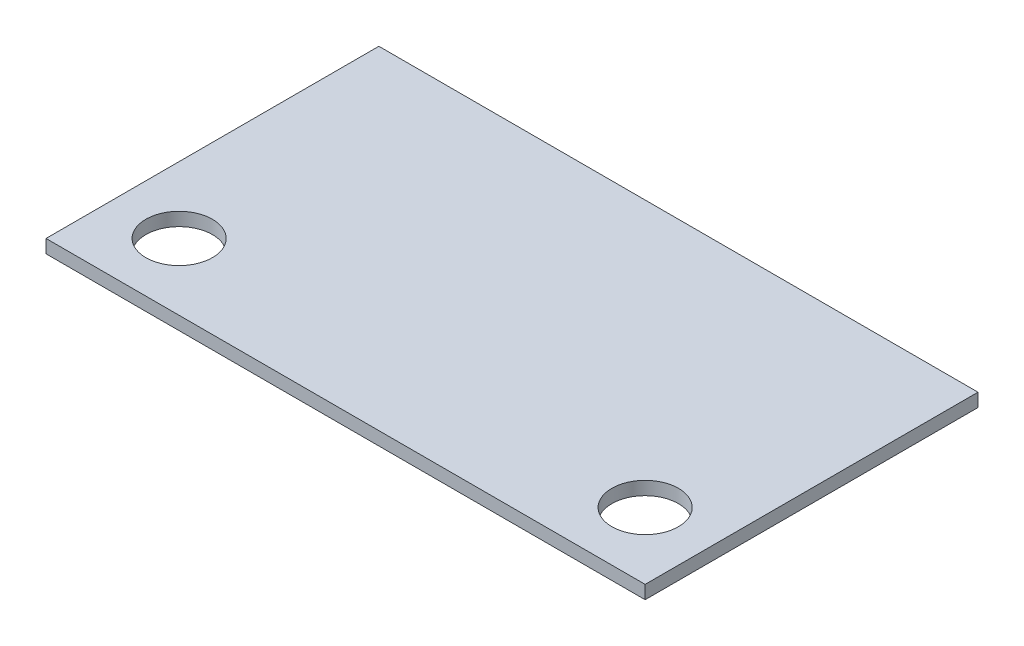
from build123d import *

# Parameters (mm, degrees)
SKETCH1_W           = 90
SKETCH1_H           = 50
SKETCH1_R           = 5
BOSS_EXTRUDE1_DEPTH = 2


with BuildPart() as part:
    # Sketch1 → Boss-Extrude1 (new body)
    with BuildSketch(Plane(origin=(0, 0, 0), x_dir=(1, 0, 0), z_dir=(0, 1, 0))):
        with Locations((7.46031746, -6.031746032)):
            Rectangle(SKETCH1_W, SKETCH1_H)
        with Locations((-27.53968254, -21.031746032)):
            Circle(SKETCH1_R, mode=Mode.SUBTRACT)
        with Locations((42.46031746, -21.031746032)):
            Circle(SKETCH1_R, mode=Mode.SUBTRACT)
    extrude(amount=BOSS_EXTRUDE1_DEPTH)


solid = part.part
